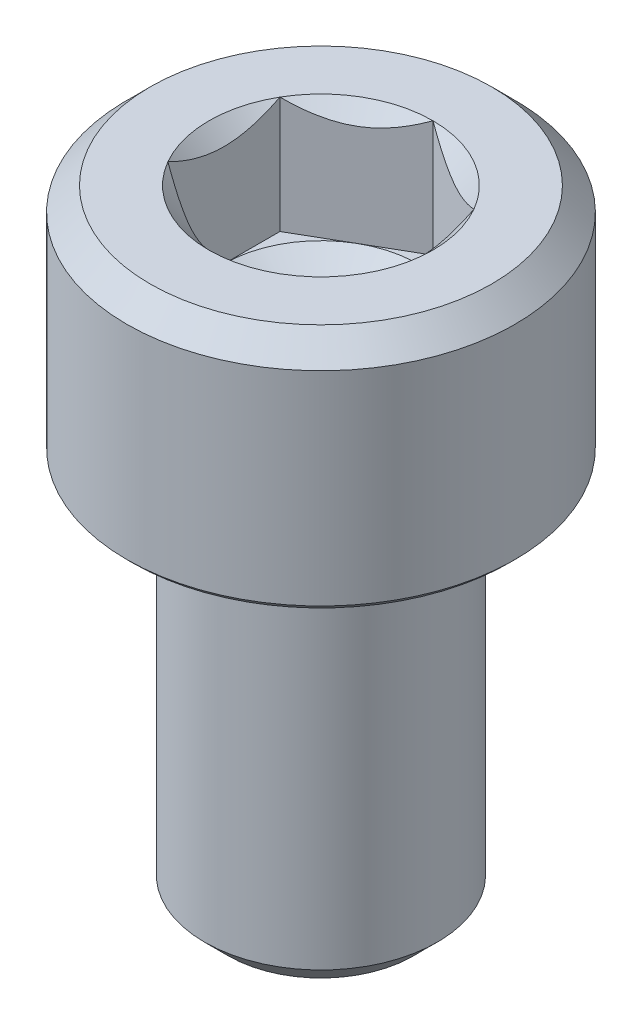
from build123d import *

# Parameters (mm, degrees)
CUT_EXTRUDE1_DEPTH = 3


with BuildPart() as part:
    # Sketch1 → Revolve1 (revolve)
    with BuildSketch(Plane.XY):
        Polygon((0, 1.556624327), (2.5, 3), (2.5, 5.613248654), (2.886751346, 6), (4.4, 6), (5, 5.4), (5, 0.15), (4.85, 0), (3.05, 0), (3, -0.68), (3, -9.3865), (2.3865, -10), (0, -10), align=None)
    revolve(axis=Axis((0, -10, 0), (0, 1, 0)))

    # Sketch2 → Cut-Extrude1 (cut)
    with BuildSketch(Plane(origin=(0, 6, 0), x_dir=(1, 0, 0), z_dir=(0, 1, 0))):
        Polygon((-2.5, -1.443375673), (0, -2.886751346), (2.5, -1.443375673), (2.5, 1.443375673), (0, 2.886751346), (-2.5, 1.443375673), align=None)
    extrude(amount=-CUT_EXTRUDE1_DEPTH, mode=Mode.SUBTRACT)


solid = part.part
